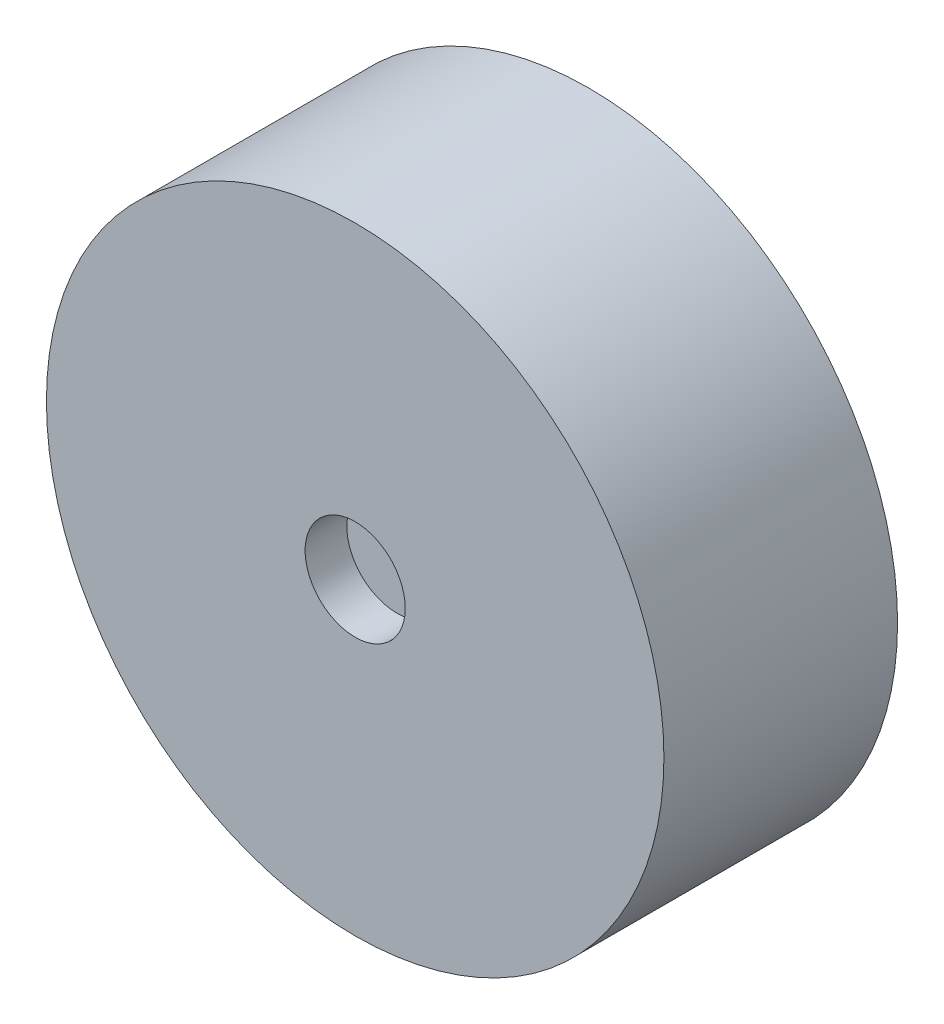
from build123d import *

# Parameters (mm, degrees)
SKETCH_1_R          = 18.5
EXTRUDE_1_DEPTH     = 14
SKETCH_2_R          = 3
CUT_EXTRUDE_1_DEPTH = 2.5
SKETCH_3_R          = 3
CUT_EXTRUDE_2_DEPTH = 2.5


with BuildPart() as part:
    # 草图1 → 凸台-拉伸1 (new body)
    with BuildSketch(Plane.XY):
        Circle(SKETCH_1_R)
    extrude(amount=EXTRUDE_1_DEPTH)

    # 草图2 → 切除-拉伸1 (cut)
    with BuildSketch(Plane(origin=(0, 0, 0), x_dir=(-1, 0, 0), z_dir=(0, 0, -1))):
        Circle(SKETCH_2_R)
    extrude(amount=-CUT_EXTRUDE_1_DEPTH, mode=Mode.SUBTRACT)

    # 草图3 → 切除-拉伸2 (cut)
    with BuildSketch(Plane.XY.offset(14)):
        Circle(SKETCH_3_R)
    extrude(amount=-CUT_EXTRUDE_2_DEPTH, mode=Mode.SUBTRACT)


solid = part.part
